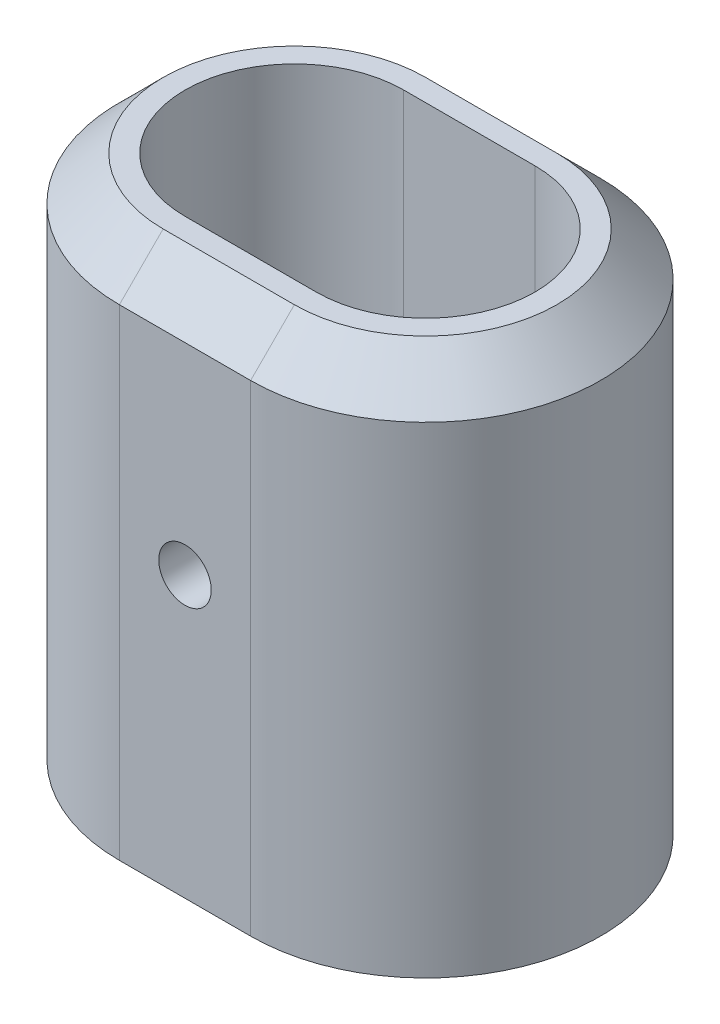
from build123d import *

# Parameters (mm, degrees)
SALIENTE_EXTRUIR1_DEPTH = 60
CHAFL_N1_SIZE           = 5
CROQUIS2_R              = 3
CORTAR_EXTRUIR1_DEPTH   = 40


with BuildPart() as part:
    # Croquis1 → Saliente-Extruir1 (new body)
    with BuildSketch(Plane(origin=(0, 0, 0), x_dir=(1, 0, 0), z_dir=(0, 1, 0))):
        with BuildLine():
            Line((0, 20), (15, 20))
            ThreePointArc((15, 20), (35, 0), (15, -20))
            Line((15, -20), (0, -20))
            ThreePointArc((0, -20), (-20, 0), (0, 20))
        make_face()
        with BuildLine():
            Line((0, 12.5), (15, 12.5))
            ThreePointArc((15, 12.5), (27.5, 0), (15, -12.5))
            Line((15, -12.5), (0, -12.5))
            ThreePointArc((0, -12.5), (-12.5, 0), (0, 12.5))
        make_face(mode=Mode.SUBTRACT)
    extrude(amount=SALIENTE_EXTRUIR1_DEPTH)

    # Chaflán1
    chafl_n1_edges = [part.edges().sort_by_distance(p)[0] for p in [
        (35, 60, 0),
        (7.5, 60, -20),
        (-20, 60, 0),
        (7.5, 60, 20),
    ]]
    chamfer(chafl_n1_edges, length=CHAFL_N1_SIZE)

    # Croquis2 → Cortar-Extruir1 (cut)
    with BuildSketch(Plane.XY.offset(20)):
        with Locations((7.5, 32)):
            Circle(CROQUIS2_R)
    extrude(amount=-CORTAR_EXTRUIR1_DEPTH, mode=Mode.SUBTRACT)


solid = part.part
